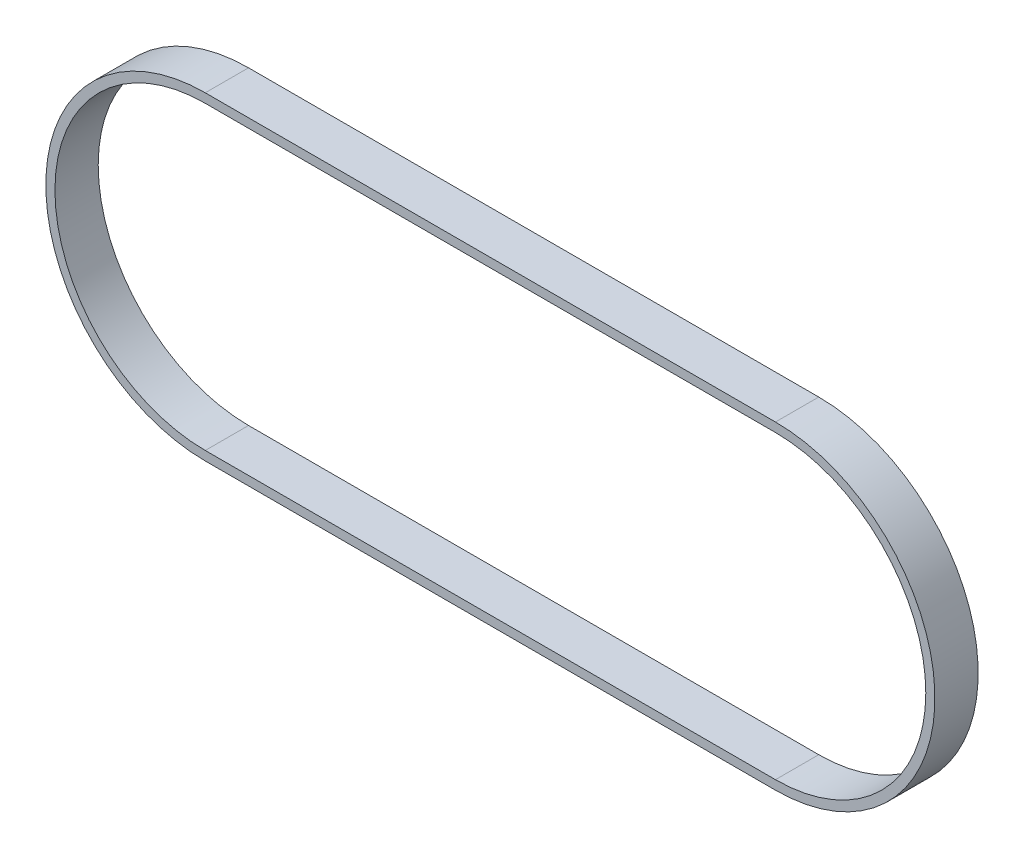
from build123d import *

# Parameters (mm, degrees)
EXTRUDE_THIN2_DEPTH      = 4.75
EXTRUDE_THIN2_DEPTH_BACK = 4.75


with BuildPart() as part:
    # Sketch2 → Extrude-Thin2 (new, two sides)
    with BuildSketch(Plane.XY) as extrude_thin2_sk:
        with BuildLine():
            Line((-125.18, 35), (0, 35))
            ThreePointArc((0, 35), (35, 0), (0, -35))
            Line((0, -35), (-125.18, -35))
            ThreePointArc((-125.18, -35), (-160.18, 0), (-125.18, 35))
        make_face()
        with BuildLine():
            Line((-125.18, 33), (0, 33))
            ThreePointArc((0, 33), (33, 0), (0, -33))
            Line((0, -33), (-125.18, -33))
            ThreePointArc((-125.18, -33), (-158.18, 0), (-125.18, 33))
        make_face(mode=Mode.SUBTRACT)
    extrude(amount=EXTRUDE_THIN2_DEPTH)
    extrude(extrude_thin2_sk.sketch, amount=-EXTRUDE_THIN2_DEPTH_BACK)


solid = part.part
